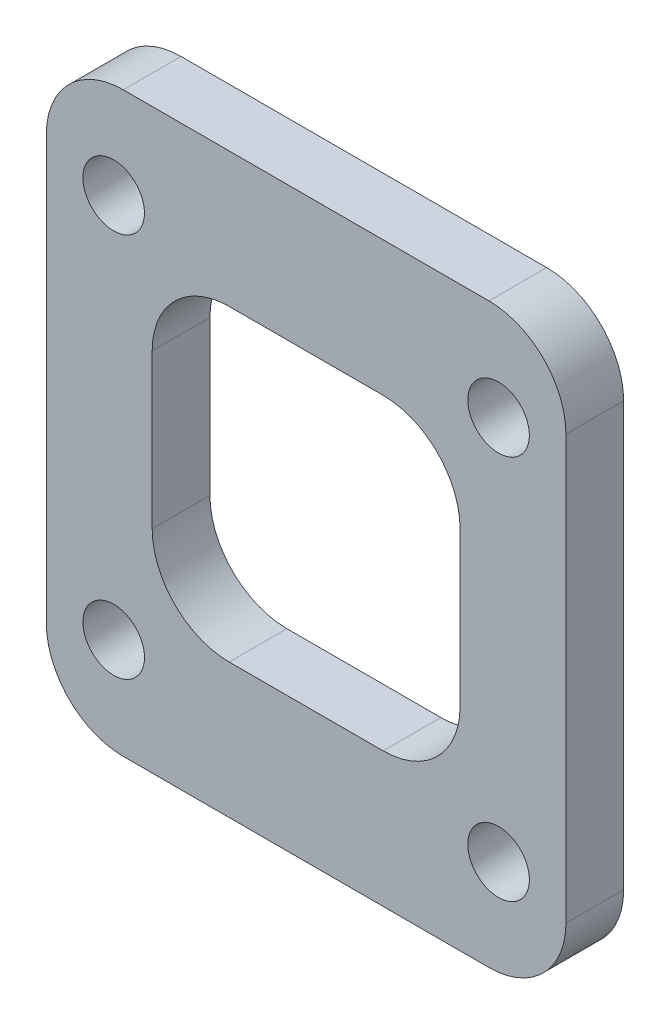
from build123d import *

# Parameters (mm, degrees)
SKETCH_1_W          = 27
SKETCH_1_H          = 30
SKETCH_1_R          = 1.6
EXTRUDE_1_DEPTH     = 3
SKETCH_2_W          = 16
SKETCH_2_H          = 16
CUT_EXTRUDE_1_DEPTH = 4
FILLET_1_R          = 4


with BuildPart() as part:
    # 草图1 → 凸台-拉伸1 (new body)
    with BuildSketch(Plane.XY):
        Rectangle(SKETCH_1_W, SKETCH_1_H)
        with Locations((10, 10)):
            Circle(SKETCH_1_R, mode=Mode.SUBTRACT)
        with Locations((10, -10)):
            Circle(SKETCH_1_R, mode=Mode.SUBTRACT)
        with Locations((-10, -10)):
            Circle(SKETCH_1_R, mode=Mode.SUBTRACT)
        with Locations((-10, 10)):
            Circle(SKETCH_1_R, mode=Mode.SUBTRACT)
    extrude(amount=EXTRUDE_1_DEPTH)

    # 草图2 → 切除-拉伸1 (cut, through all)
    with BuildSketch(Plane.XY.offset(3)):
        Rectangle(SKETCH_2_W, SKETCH_2_H)
    extrude(amount=-CUT_EXTRUDE_1_DEPTH, mode=Mode.SUBTRACT)

    # 圆角1
    fillet_1_edges = [part.edges().sort_by_distance(p)[0] for p in [
        (8, 8, 1.5),
        (8, -8, 1.5),
        (-8, -8, 1.5),
        (-8, 8, 1.5),
        (13.5, -15, 1.5),
        (-13.5, -15, 1.5),
        (-13.5, 15, 1.5),
        (13.5, 15, 1.5),
    ]]
    fillet(fillet_1_edges, radius=FILLET_1_R)


solid = part.part
